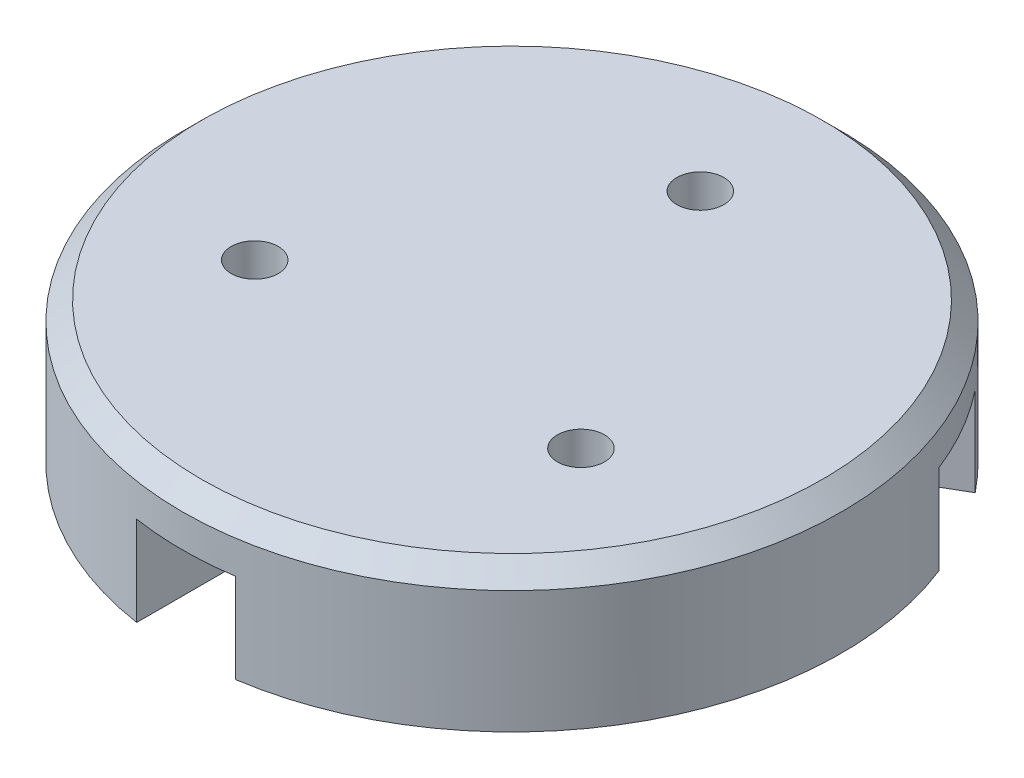
from build123d import *

# Parameters (mm, degrees)
SKETCH_1_R               = 7
EXTRUDE_1_DEPTH          = 3
SKETCH_2_W               = 2.1
SKETCH_2_H               = 10
CUT_EXTRUDE_1_DEPTH      = 1.9
SKETCH_3_R               = 1.05
CUT_EXTRUDE_2_DEPTH      = 1
CUT_EXTRUDE_2_DEPTH_BACK = 2.5
SKETCH_4_R               = 0.5
CUT_EXTRUDE_3_DEPTH      = 1
CUT_EXTRUDE_3_DEPTH_BACK = 4
CHAMFER_1_SIZE           = 0.4


with BuildPart() as part:
    # Эскиз1 → Бобышка-Вытянуть1 (new body)
    with BuildSketch(Plane(origin=(0, 0, 0), x_dir=(1, 0, 0), z_dir=(0, 1, 0))):
        Circle(SKETCH_1_R)
    extrude(amount=EXTRUDE_1_DEPTH)

    # Эскиз2 → Вырез-Вытянуть1 (cut)
    with BuildSketch(Plane.XZ):
        Polygon((10.917234456, -5.090702278), (9.867234456, -6.909355626), (1.206980418, -1.909355626), (2.256980418, -0.090702278), align=None)
        with Locations((-7.039e-05, 6.999971048)):
            Rectangle(SKETCH_2_W, SKETCH_2_H)
        Polygon((-9.867375235, -6.909355626), (-10.917375235, -5.090702278), (-2.257121197, -0.090702278), (-1.207121197, -1.909355626), align=None)
    extrude(amount=-CUT_EXTRUDE_1_DEPTH, mode=Mode.SUBTRACT)

    # Эскиз3 → Вырез-Вытянуть2 (cut, two sides)
    with BuildSketch(Plane.XZ) as cut_extrude_2_sk:
        Circle(SKETCH_3_R)
    extrude(amount=CUT_EXTRUDE_2_DEPTH, mode=Mode.SUBTRACT)
    extrude(cut_extrude_2_sk.sketch, amount=-CUT_EXTRUDE_2_DEPTH_BACK, mode=Mode.SUBTRACT)

    # Эскиз4 → Вырез-Вытянуть3 (cut, two sides)
    with BuildSketch(Plane.XZ) as cut_extrude_3_sk:
        with Locations((0, -4)):
            Circle(SKETCH_4_R)
        with Locations((-3.464101615, 2)):
            Circle(SKETCH_4_R)
        with Locations((3.464101615, 2)):
            Circle(SKETCH_4_R)
    extrude(amount=CUT_EXTRUDE_3_DEPTH, mode=Mode.SUBTRACT)
    extrude(cut_extrude_3_sk.sketch, amount=-CUT_EXTRUDE_3_DEPTH_BACK, mode=Mode.SUBTRACT)

    # Фаска1
    chamfer_1_edges = [part.edges().sort_by_distance(p)[0] for p in [
        (-7, 3, 0),
    ]]
    chamfer(chamfer_1_edges, length=CHAMFER_1_SIZE)


solid = part.part
